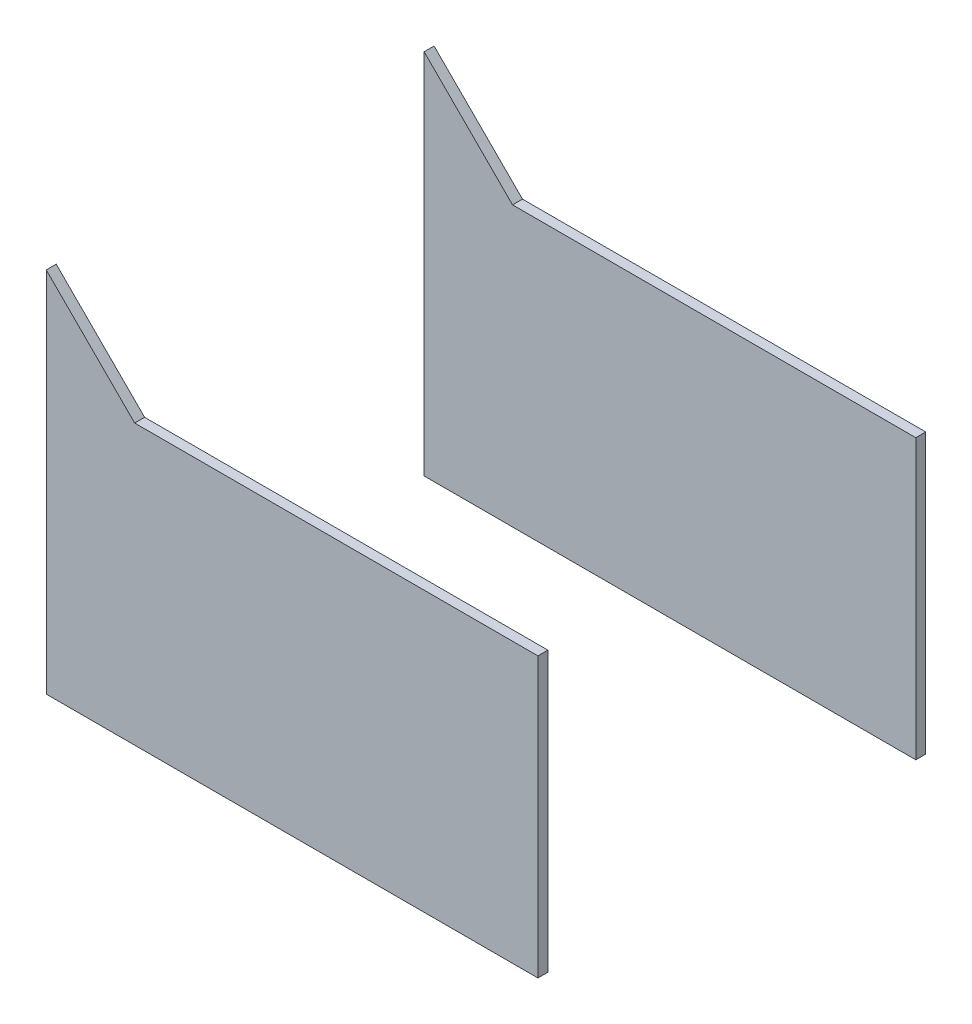
from build123d import *

# Parameters (mm, degrees)
BOSS_EXTRUDE1_START = 185
BOSS_EXTRUDE1_DEPTH = 10
BOSS_EXTRUDE2_START = -185
BOSS_EXTRUDE2_DEPTH = 10


with BuildPart() as part:
    # Sketch1 → Boss-Extrude1 (new body)
    with BuildSketch(Plane.XY.offset(BOSS_EXTRUDE1_START)):
        Polygon((-247.202646763, 184.728372851), (-247.202646763, -184.728372851), (247.202646763, -184.728372851), (247.202646763, 95.824349837), (-158.298623749, 95.824349837), align=None)
    extrude(amount=BOSS_EXTRUDE1_DEPTH)


with BuildPart() as body_2:
    # Sketch1_3 → Boss-Extrude2 (new body)
    with BuildSketch(Plane.XY.offset(BOSS_EXTRUDE2_START)):
        Polygon((-247.202646763, 184.728372851), (-247.202646763, -184.728372851), (247.202646763, -184.728372851), (247.202646763, 95.824349837), (-158.298623749, 95.824349837), align=None)
    extrude(amount=-BOSS_EXTRUDE2_DEPTH)


solid = Compound([part.part, body_2.part])
